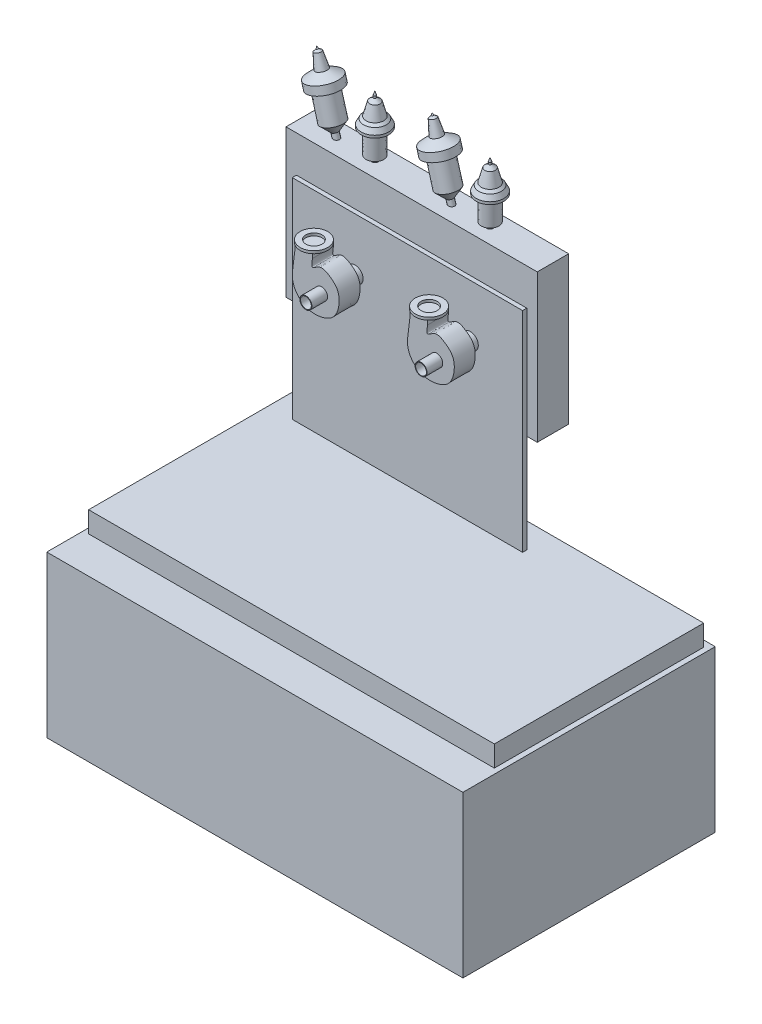
from build123d import *

# Parameters (mm, degrees)
SKETCH1_W       = 3975
SKETCH1_H       = 100
EXTRUDE1_DEPTH  = 2410
SKETCH2_W       = 3875
SKETCH2_H       = 2000
EXTRUDE2_DEPTH  = 200
SKETCH3_W       = 2400
SKETCH3_H       = 1410
EXTRUDE3_DEPTH  = 300
SHELL1_T        = -10
SKETCH4_W       = 2200
SKETCH4_H       = 2000
EXTRUDE4_DEPTH  = 40
EXTRUDE5_DEPTH  = 30
SKETCH6_R       = 90.335637297
SKETCH6_R_2     = 185.994110547
EXTRUDE6_DEPTH  = 250
EXTRUDE7_DEPTH  = 50
SKETCH8_R       = 84
SKETCH8_R_2     = 77
SKETCH8_R_3     = 57.15
SKETCH8_R_4     = 48.6
EXTRUDE8_DEPTH  = 127
LPATTERN1_COUNT = 2
LPATTERN1_PITCH = 1100
SKETCH11_R      = 77
EXTRUDE9_DEPTH  = 530
EXTRUDE10_START = 120
EXTRUDE10_DEPTH = 200
SKETCH13_R      = 57.4
SKETCH13_R_2    = 51.8
EXTRUDE11_DEPTH = 150
SKETCH14_R      = 131.858365534
SKETCH14_R_2    = 77
EXTRUDE12_DEPTH = 25
LPATTERN2_COUNT = 2
LPATTERN2_PITCH = 1100
SKETCH15_W      = 3975
SKETCH15_H      = 2410
EXTRUDE13_DEPTH = 1436.15


with BuildPart() as part:
    # Sketch1 → Extrude1 (new body)
    with BuildSketch(Plane.XY):
        with Locations((1062.5, 50)):
            Rectangle(SKETCH1_W, SKETCH1_H)
    extrude(amount=EXTRUDE1_DEPTH)

    # Sketch2 → Extrude2 (add)
    with BuildSketch(Plane(origin=(0, 100, 0), x_dir=(1, 0, 0), z_dir=(0, 1, 0))):
        with Locations((1062.5, -1060)):
            Rectangle(SKETCH2_W, SKETCH2_H)
    extrude(amount=EXTRUDE2_DEPTH)



with BuildPart() as body_2:
    # Sketch3 → Extrude3 (new body)
    with BuildSketch(Plane(origin=(0, 0, 0), x_dir=(-1, 0, 0), z_dir=(0, 0, -1))):
        with Locations((-450, 1945)):
            Rectangle(SKETCH3_W, SKETCH3_H)
    extrude(amount=-EXTRUDE3_DEPTH)

    # Shell1
    shell1_openings = [body_2.faces().sort_by_distance(p)[0] for p in [
        (450, 1945, 0),
    ]]
    offset(amount=SHELL1_T, openings=shell1_openings, kind=Kind.INTERSECTION)


with BuildPart() as part_1:
    add(part.part)

    add(body_2.part)  # Extrude4 merges body 2
    # Sketch4 → Extrude4 (add)
    with BuildSketch(Plane.XY.offset(300)):
        with Locations((450, 1300)):
            Rectangle(SKETCH4_W, SKETCH4_H)
    extrude(amount=EXTRUDE4_DEPTH)

    # Sketch5 → Extrude5 (add)
    with BuildSketch(Plane(origin=(0, 0, 290), x_dir=(-1, 0, 0), z_dir=(0, 0, -1))):
        with BuildLine():
            ThreePointArc((-43.381911556, 2031.904761905), (50, 1550), (143.381911556, 2031.904761905))
            ThreePointArc((143.381911556, 2031.904761905), (50, 2240), (-43.381911556, 2031.904761905))
        make_face()
    extrude5 = extrude(amount=EXTRUDE5_DEPTH)

    # Sketch6 → Extrude6 (add)
    with BuildSketch(Plane(origin=(0, 0, 260), x_dir=(-1, 0, 0), z_dir=(0, 0, -1))):
        with Locations((50, 2115)):
            Circle(SKETCH6_R)
        with Locations((50, 1836.581150081)):
            Circle(SKETCH6_R_2)
    extrude6 = extrude(amount=EXTRUDE6_DEPTH)

    # Sketch7 → Extrude7 (add)
    with BuildSketch(Plane(origin=(0, 0, 10), x_dir=(-1, 0, 0), z_dir=(0, 0, -1))):
        with BuildLine():
            Line((42.5, 2024.976239993), (42.5, 1949.22460506))
            ThreePointArc((42.5, 1949.22460506), (42.461818703, 1650.777318821), (72.5, 1947.709115343))
            Line((72.5, 1947.709115343), (72.5, 2027.511272921))
            ThreePointArc((72.5, 2027.511272921), (42.393647524, 2205.014836376), (42.5, 2024.976239993))
        make_face()
    extrude7 = extrude(amount=EXTRUDE7_DEPTH)

    # Sketch8 → Extrude8 (add)
    with BuildSketch(Plane(origin=(0, 0, -40), x_dir=(-1, 0, 0), z_dir=(0, 0, -1))):
        with Locations((50, 1800)):
            Circle(SKETCH8_R)
        with Locations((50, 1800)):
            Circle(SKETCH8_R_2, mode=Mode.SUBTRACT)
        with Locations((50, 2115)):
            Circle(SKETCH8_R_3)
        with Locations((50, 2115)):
            Circle(SKETCH8_R_4, mode=Mode.SUBTRACT)
    extrude8 = extrude(amount=EXTRUDE8_DEPTH)

    # Sketch9 → Revolve2 (revolve)
    with BuildSketch(Plane.XY.offset(150), mode=Mode.PRIVATE) as revolve2_sk:
        Polygon((-50, 2115), (-19.7824166, 2115), (-19.7824166, 2668.294027906), (32.643105037, 2695.337009218), (32.643105037, 2923.625661757), (80.934935381, 2923.625661757), (80.934935381, 2947.771576929), (56.789020209, 2994.580846354), (32.643105037, 3015.819156051), (-1.4, 3138.74381511), (-38.625885396, 3167.488636683), (-38.41598829, 3186.911187484), (-50.770056468, 3222.156976615), align=None)
    revolve2 = revolve(revolve2_sk.sketch.rotate(Axis((-50.770056468, 3222.156976615, 150), (0.0006955258358452618, -0.9999997581218766, 0)), 180), axis=Axis((-50.770056468, 3222.156976615, 150), (0.0006955258358452618, -0.9999997581218766, 0)))

    # Sketch10 → Revolve3 (revolve)
    with BuildSketch(Plane.XY.offset(150), mode=Mode.PRIVATE) as revolve3_sk:
        Polygon((-104.208631161, 1648.863218862), (-403.441978098, 2703.983731757), (-352.97825639, 2798.369475086), (-420.196068372, 3035.384811046), (-378.303194256, 3063.503361634), (-399.275859485, 3137.454642532), (-506.998867931, 3164.75357328), (-563.181096984, 3288.367677028), (-591.005955425, 3298.318124132), (-605.682241358, 3315.749641826), (-135.461043793, 1640), align=None)
    revolve3 = revolve(revolve3_sk.sketch.rotate(Axis((-605.682241358, 3315.749641826, 150), (0.2701686888106616, -0.9628130034364555, 0)), 180), axis=Axis((-605.682241358, 3315.749641826, 150), (0.2701686888106616, -0.9628130034364555, 0)))

    # LPattern1: Extrude5, Extrude6, Extrude7, Extrude8, Revolve2, Revolve3 ×2
    with Locations(*[(i * LPATTERN1_PITCH, 0, 0) for i in range(1, LPATTERN1_COUNT)]):
        add(extrude5)
        add(extrude6)
        add(extrude7)
        add(extrude8)
        add(revolve2)
        add(revolve3)

    # Sketch11 → Extrude9 (add)
    with BuildSketch(Plane(origin=(0, 0, -40), x_dir=(-1, 0, 0), z_dir=(0, 0, -1))):
        with Locations((-1050, 1800)):
            Circle(SKETCH11_R)
        with Locations((50, 1800)):
            Circle(SKETCH11_R)
    extrude(amount=-EXTRUDE9_DEPTH)

    # Sketch12 → Extrude10 (add)
    with BuildSketch(Plane.XY.offset(340).offset(EXTRUDE10_START)):
        with BuildLine():
            Line((-136.907452595, 2086.652556212), (-136.907452595, 2048.105164106))
            add(Edge.make_bspline(
                [(-303.143081055, 2048.105164106), (-309.568639692, 1998.664650162), (-322.058567414, 1902.562742037), (-341.738406813, 1744.748232219), (-226.857560375, 1599.247632832), (-58.417205194, 1590.91237653), (76.640252222, 1655.357699102), (122.905604965, 1780.291955984), (118.258284737, 1910.210371456), (29.251446781, 1986.084304652), (-61.934168453, 2036.015672567), (-153.698426308, 1943.038362332), (-142.649343375, 2012.1762114), (-136.907452595, 2048.105164106)],
                knots=[0, 0, 0, 0, 0.110147792, 0.214104025, 0.337658837, 0.464242007, 0.556489174, 0.644869142, 0.742352434, 0.817106492, 0.894893029, 0.945378929, 1, 1, 1, 1], degree=3))
            Line((-303.143081055, 2048.105164106), (-303.143081055, 2086.652556212))
            Line((-303.143081055, 2086.652556212), (-136.907452595, 2086.652556212))
        make_face()
    extrude10 = extrude(amount=EXTRUDE10_DEPTH)

    # Sketch13 → Extrude11 (add)
    with BuildSketch(Plane.XY.offset(660)):
        with Locations(Location((-50, 1800, 0), (0, 0, 180))):
            Circle(SKETCH13_R)
        with Locations((-50, 1800)):
            Circle(SKETCH13_R_2, mode=Mode.SUBTRACT)
    extrude11 = extrude(amount=EXTRUDE11_DEPTH)

    # Sketch14 → Extrude12 (add)
    with BuildSketch(Plane(origin=(0, 2086.652556212, 0), x_dir=(1, 0, 0), z_dir=(0, 1, 0))):
        with Locations(Location((-222.986833858, -560.115222968, 0), (0, 0, 49.399298505))):
            Circle(SKETCH14_R)
        with Locations(Location((-222.986833858, -560.115222968, 0), (0, 0, 270))):
            Circle(SKETCH14_R_2, mode=Mode.SUBTRACT)
    extrude12 = extrude(amount=EXTRUDE12_DEPTH)

    # LPattern2: Extrude10, Extrude11, Extrude12 ×2
    with Locations(*[(i * LPATTERN2_PITCH, 0, 0) for i in range(1, LPATTERN2_COUNT)]):
        add(extrude10)
        add(extrude11)
        add(extrude12)

    # Sketch15 → Extrude13 (add)
    with BuildSketch(Plane.XZ):
        with Locations((1062.5, 1205)):
            Rectangle(SKETCH15_W, SKETCH15_H)
    extrude(amount=EXTRUDE13_DEPTH)


solid = part_1.part
